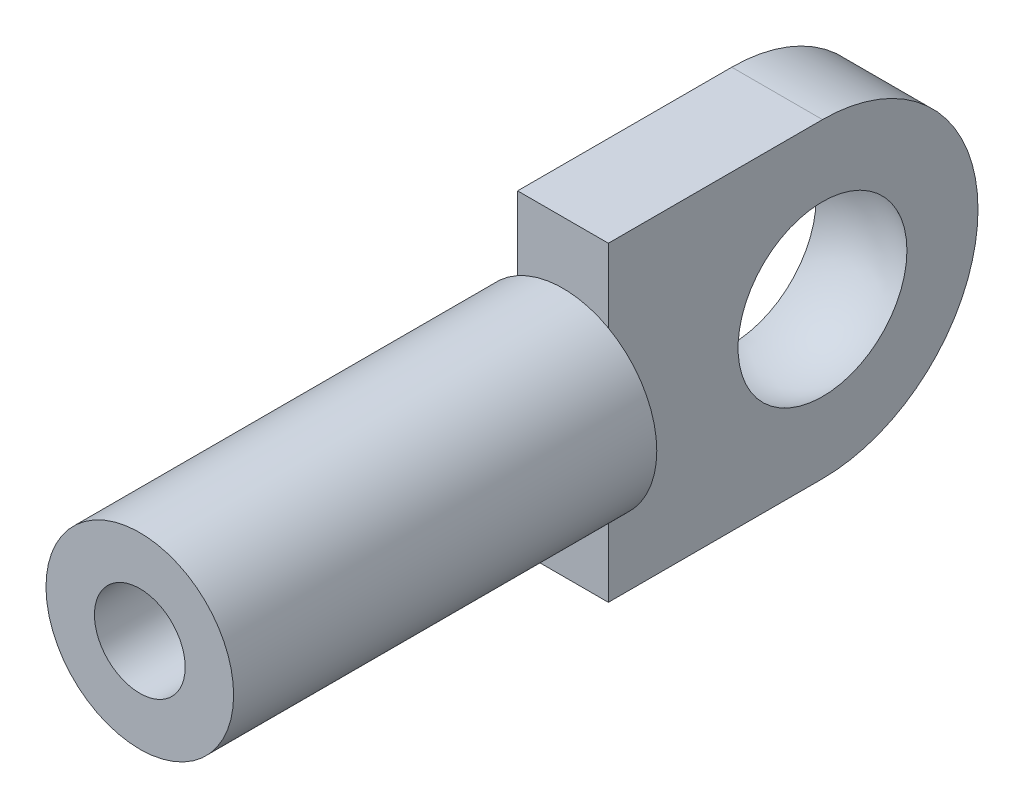
from build123d import *

# Parameters (mm, degrees)
SKETCH1_R           = 2.3368
EXTRUDE1_DEPTH      = 10.541
EXTRUDE2_DEPTH      = 1.1303
EXTRUDE2_DEPTH_BACK = 1.1303
SKETCH4_R           = 1.1303
EXTRUDE3_DEPTH      = 8.001


with BuildPart() as part:
    # Sketch1 → Extrude1 (new body)
    with BuildSketch(Plane.XY):
        Circle(SKETCH1_R)
    extrude(amount=EXTRUDE1_DEPTH)

    # Sketch2 → Extrude2 (add, two sides)
    with BuildSketch(Plane(origin=(0, 0, 0), x_dir=(0, 0, -1), z_dir=(1, 0, 0))) as extrude2_sk:
        with BuildLine():
            Line((0, 0), (0, 3.8735))
            Line((0, 3.8735), (5.334, 3.8735))
            ThreePointArc((5.334, 3.8735), (9.2075, 0), (5.334, -3.8735))
            Line((5.334, -3.8735), (0, -3.8735))
            Line((0, -3.8735), (0, 0))
        make_face()
    extrude(amount=EXTRUDE2_DEPTH)
    extrude(extrude2_sk.sketch, amount=-EXTRUDE2_DEPTH_BACK)

    # Sketch3 → Cut-Revolve1 (revolve, cut)
    with BuildSketch(Plane(origin=(0, 0, 0), x_dir=(0, 0, -1), z_dir=(1, 0, 0))):
        with BuildLine():
            Line((5.334, 2.3876), (5.334, -2.3876))
            ThreePointArc((5.334, -2.3876), (2.9464, 0), (5.334, 2.3876))
        make_face()
    revolve(axis=Axis((0, 2.3876, -5.334), (0, -1, 0)), mode=Mode.SUBTRACT)

    # Sketch4 → Extrude3 (cut)
    with BuildSketch(Plane.XY.offset(10.541)):
        Circle(SKETCH4_R)
    extrude(amount=-EXTRUDE3_DEPTH, mode=Mode.SUBTRACT)


solid = part.part
